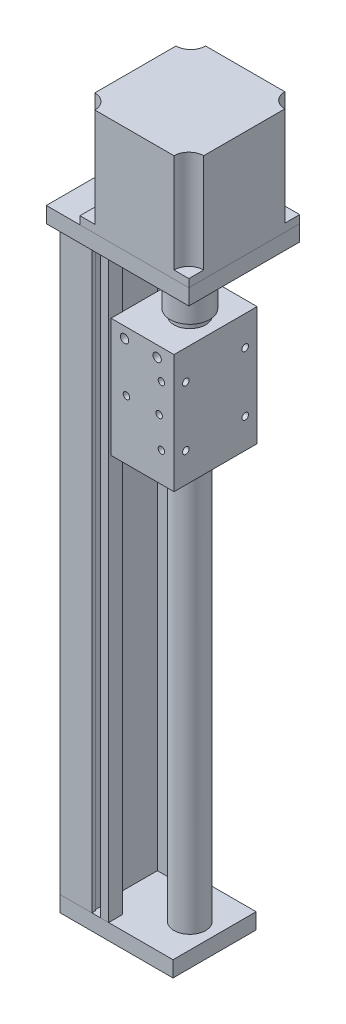
from build123d import *

# Parameters (mm, degrees)
SKETCH1_W                      = 57
SKETCH1_H                      = 42
BOSS_EXTRUDE1_DEPTH            = 8
BOSS_EXTRUDE2_DEPTH            = 297
SKETCH3_W                      = 72
SKETCH3_H                      = 56
BOSS_EXTRUDE3_DEPTH            = 8
SKETCH4_W                      = 55
SKETCH4_H                      = 56
BOSS_EXTRUDE4_DEPTH            = 54
CUT_EXTRUDE1_DEPTH             = 50
SKETCH6_R                      = 8
BOSS_EXTRUDE5_DEPTH            = 268.3
SKETCH7_W                      = 31.8
SKETCH7_H                      = 42
BOSS_EXTRUDE6_DEPTH            = 30
SKETCH8_R                      = 10
BOSS_EXTRUDE7_DEPTH            = 25
SKETCH9_R                      = 15
CUT_EXTRUDE2_DEPTH             = 5
BOSS_EXTRUDE8_REACH            = 67.7
SKETCH10_R                     = 3.175
SKETCH11_W                     = 4.3
SKETCH11_H                     = 297
CUT_EXTRUDE3_DEPTH             = 5.4
SKETCH12_W                     = 3.6
SKETCH12_H                     = 297
CUT_EXTRUDE4_DEPTH             = 2.7
SKETCH13_W                     = 4.3
SKETCH13_H                     = 297
CUT_EXTRUDE5_DEPTH             = 6.8
SKETCH14_W                     = 3.3
SKETCH14_H                     = 297
CUT_EXTRUDE6_DEPTH             = 3.4
M4X0_7_TAPPED_HOLE1_D          = 3.3
M4X0_7_TAPPED_HOLE1_DEPTH      = 10.1
M4X0_7_TAPPED_HOLE1_TIP        = 0.991420021
M4X0_7_TAPPED_HOLE2_AT_2_COUNT = 2
M4X0_7_TAPPED_HOLE2_AT_2_PITCH = 30
M4X0_7_TAPPED_HOLE2_AT_3_COUNT = 2
M4X0_7_TAPPED_HOLE2_AT_3_PITCH = 15.044018745
M4X0_7_TAPPED_HOLE2_AT_4_COUNT = 2
M4X0_7_TAPPED_HOLE2_AT_4_PITCH = 23.162955338
M5X0_8_TAPPED_HOLE1_AT_2_COUNT = 2
M5X0_8_TAPPED_HOLE1_AT_2_PITCH = 16.5


with BuildPart() as part:
    # Sketch1 → Boss-Extrude1 (new body)
    with BuildSketch(Plane(origin=(0, 0, 0), x_dir=(1, 0, 0), z_dir=(0, 1, 0))):
        with Locations((28.5, 0)):
            Rectangle(SKETCH1_W, SKETCH1_H)
    extrude(amount=BOSS_EXTRUDE1_DEPTH)

    # Sketch2 → Boss-Extrude2 (add)
    with BuildSketch(Plane(origin=(0, 8, 0), x_dir=(1, 0, 0), z_dir=(0, 1, 0))):
        Polygon((0, 21), (0, -21), (24.5, -21), (24.5, -14), (14.1, -14), (14.1, 14), (24.5, 14), (24.5, 21), align=None)
    extrude(amount=BOSS_EXTRUDE2_DEPTH)

    # Sketch3 → Boss-Extrude3 (add)
    with BuildSketch(Plane(origin=(0, 305, 0), x_dir=(1, 0, 0), z_dir=(0, 1, 0))):
        with Locations((36, 0)):
            Rectangle(SKETCH3_W, SKETCH3_H)
    extrude(amount=BOSS_EXTRUDE3_DEPTH)

    # Sketch4 → Boss-Extrude4 (add)
    with BuildSketch(Plane(origin=(0, 313, 0), x_dir=(1, 0, 0), z_dir=(0, 1, 0))):
        with Locations((44.5, 0)):
            Rectangle(SKETCH4_W, SKETCH4_H)
    extrude(amount=BOSS_EXTRUDE4_DEPTH)

    # Sketch5 → Cut-Extrude1 (cut)
    with BuildSketch(Plane(origin=(0, 367, 0), x_dir=(1, 0, 0), z_dir=(0, 1, 0))):
        with BuildLine():
            Line((17, 28), (17, 20.5))
            ThreePointArc((17, 20.5), (22.303300859, 22.696699141), (24.5, 28))
            Line((24.5, 28), (17, 28))
        make_face()
        with BuildLine():
            Line((72, 28), (64.5, 28))
            ThreePointArc((64.5, 28), (66.696699141, 22.696699141), (72, 20.5))
            Line((72, 20.5), (72, 28))
        make_face()
        with BuildLine():
            Line((72, -28), (72, -20.5))
            ThreePointArc((72, -20.5), (66.696699141, -22.696699141), (64.5, -28))
            Line((64.5, -28), (72, -28))
        make_face()
        with BuildLine():
            Line((17, -28), (24.5, -28))
            ThreePointArc((24.5, -28), (22.303300859, -22.696699141), (17, -20.5))
            Line((17, -20.5), (17, -28))
        make_face()
    extrude(amount=-CUT_EXTRUDE1_DEPTH, mode=Mode.SUBTRACT)

    # Sketch6 → Boss-Extrude5 (add)
    with BuildSketch(Plane(origin=(0, 8, 0), x_dir=(1, 0, 0), z_dir=(0, 1, 0))):
        with Locations((44.5, 0)):
            Circle(SKETCH6_R)
    extrude(amount=BOSS_EXTRUDE5_DEPTH)

    # Sketch7 → Boss-Extrude6 (add, symmetric)
    with BuildSketch(Plane(origin=(0, 243, 0), x_dir=(1, 0, 0), z_dir=(0, 1, 0))):
        with Locations((41.6, 0)):
            Rectangle(SKETCH7_W, SKETCH7_H)
    extrude(amount=BOSS_EXTRUDE6_DEPTH, both=True)

    # Sketch8 → Boss-Extrude7 (add)
    with BuildSketch(Plane(origin=(0, 276.3, 0), x_dir=(1, 0, 0), z_dir=(0, 1, 0))):
        with Locations((44.5, 0)):
            Circle(SKETCH8_R)
    extrude(amount=BOSS_EXTRUDE7_DEPTH)

    # Sketch9 → Cut-Extrude2 (cut)
    with BuildSketch(Plane.XZ.offset(-305)):
        with Locations((44.5, 0)):
            Circle(SKETCH9_R)
    extrude(amount=-CUT_EXTRUDE2_DEPTH, mode=Mode.SUBTRACT)

    # Sketch10 → Boss-Extrude8 (add, up to next)
    with BuildSketch(Plane(origin=(0, 301.3, 0), x_dir=(1, 0, 0), z_dir=(0, 1, 0)), mode=Mode.PRIVATE) as boss_extrude8_sk1:
        with Locations((44.5, 0)):
            Circle(SKETCH10_R)
    boss_extrude8_tool1 = extrude(boss_extrude8_sk1.sketch, amount=BOSS_EXTRUDE8_REACH, mode=Mode.PRIVATE) - part.part
    add(boss_extrude8_tool1.solids().sort_by_distance((44.5, 301.3, 0))[0])

    # Sketch11 → Cut-Extrude3 (cut)
    with BuildSketch(Plane(origin=(0, 0, -21), x_dir=(-1, 0, 0), z_dir=(0, 0, -1))):
        with Locations((-18.15, 156.5)):
            Rectangle(SKETCH11_W, SKETCH11_H)
    cut_extrude3 = extrude(amount=-CUT_EXTRUDE3_DEPTH, mode=Mode.SUBTRACT)

    # Sketch12 → Cut-Extrude4 (cut, symmetric)
    with BuildSketch(Plane(origin=(18.15, 0, 0), x_dir=(0, 0, -1), z_dir=(1, 0, 0))):
        with Locations((17.4, 156.5)):
            Rectangle(SKETCH12_W, SKETCH12_H)
    cut_extrude4 = extrude(amount=CUT_EXTRUDE4_DEPTH, both=True, mode=Mode.SUBTRACT)

    # Mirror1: Cut-Extrude3, Cut-Extrude4 across plane
    add(cut_extrude3.mirror(Plane.XY), mode=Mode.SUBTRACT)
    add(cut_extrude4.mirror(Plane.XY), mode=Mode.SUBTRACT)

    # Sketch13 → Cut-Extrude5 (cut)
    with BuildSketch(Plane.ZY):
        with Locations((15, 156.5)):
            Rectangle(SKETCH13_W, SKETCH13_H)
    cut_extrude5 = extrude(amount=-CUT_EXTRUDE5_DEPTH, mode=Mode.SUBTRACT)

    # Sketch14 → Cut-Extrude6 (cut, symmetric)
    with BuildSketch(Plane.XY.offset(15)):
        with Locations((3.65, 156.5)):
            Rectangle(SKETCH14_W, SKETCH14_H)
    cut_extrude6 = extrude(amount=CUT_EXTRUDE6_DEPTH, both=True, mode=Mode.SUBTRACT)

    # Mirror2: Cut-Extrude5, Cut-Extrude6 across plane
    add(cut_extrude5.mirror(Plane.XY), mode=Mode.SUBTRACT)
    add(cut_extrude6.mirror(Plane.XY), mode=Mode.SUBTRACT)

    # M4x0.7 Tapped Hole1
    with Locations(Plane(origin=(57.5, 0, 0), x_dir=(0, 0, -1), z_dir=(1, 0, 0))):
        with Locations((-15, 258), (15, 258), (15, 228), (-15, 228)):
            Hole(M4X0_7_TAPPED_HOLE1_D / 2, depth=M4X0_7_TAPPED_HOLE1_DEPTH)
            with Locations((0, 0, -(M4X0_7_TAPPED_HOLE1_DEPTH + M4X0_7_TAPPED_HOLE1_TIP / 2))):  # 118° drill point
                Cone(0, M4X0_7_TAPPED_HOLE1_D / 2, M4X0_7_TAPPED_HOLE1_TIP, mode=Mode.SUBTRACT)

    # Sketch23 → M4x0.7 Tapped Hole2 (revolve, cut)
    with BuildSketch(Plane(origin=(51.15, 228, 21), x_dir=(0, -1, 0), z_dir=(1, 0, 0))):
        Polygon((0, 0), (0, 6.991420021), (1.65, 6), (1.65, 0), align=None)
    m4x0_7_tapped_hole2 = revolve(axis=Axis((51.15, 228, 27.35), (0, 0, -1)), mode=Mode.SUBTRACT)

    # M4x0.7 Tapped Hole2 at 2: M4x0.7 Tapped Hole2 ×2
    with Locations(*[(0, i * M4X0_7_TAPPED_HOLE2_AT_2_PITCH, 0) for i in range(1, M4X0_7_TAPPED_HOLE2_AT_2_COUNT)]):
        add(m4x0_7_tapped_hole2, mode=Mode.SUBTRACT)

    # M4x0.7 Tapped Hole2 at 3: M4x0.7 Tapped Hole2 ×2
    with Locations(*[Vector(-0.07644234, 0.997074004, 0) * (i * M4X0_7_TAPPED_HOLE2_AT_3_PITCH) for i in range(1, M4X0_7_TAPPED_HOLE2_AT_3_COUNT)]):
        add(m4x0_7_tapped_hole2, mode=Mode.SUBTRACT)

    # M4x0.7 Tapped Hole2 at 4: M4x0.7 Tapped Hole2 ×2
    with Locations(*[Vector(-0.761992576, 0.647585758, 0) * (i * M4X0_7_TAPPED_HOLE2_AT_4_PITCH) for i in range(1, M4X0_7_TAPPED_HOLE2_AT_4_COUNT)]):
        add(m4x0_7_tapped_hole2, mode=Mode.SUBTRACT)

    # Sketch25 → M5x0.8 Tapped Hole1 (revolve, cut)
    with BuildSketch(Plane(origin=(32.5, 267.5, 21), x_dir=(0, -1, 0), z_dir=(1, 0, 0))):
        Polygon((0, 0), (0, 11.2618073), (2.1, 10), (2.1, 0), align=None)
    m5x0_8_tapped_hole1 = revolve(axis=Axis((32.5, 267.5, 27.35), (0, 0, -1)), mode=Mode.SUBTRACT)

    # M5x0.8 Tapped Hole1 at 2: M5x0.8 Tapped Hole1 ×2
    with Locations(*[(i * M5X0_8_TAPPED_HOLE1_AT_2_PITCH, 0, 0) for i in range(1, M5X0_8_TAPPED_HOLE1_AT_2_COUNT)]):
        add(m5x0_8_tapped_hole1, mode=Mode.SUBTRACT)

    # Mirror3: M5x0.8 Tapped Hole1, M4x0.7 Tapped Hole2 across plane
    add(m5x0_8_tapped_hole1.mirror(Plane.XY), mode=Mode.SUBTRACT)
    add(m4x0_7_tapped_hole2.mirror(Plane.XY), mode=Mode.SUBTRACT)

    # Mirror3 copy 1 sketch → Mirror3 copy 1 (revolve, cut)
    with BuildSketch(Plane(origin=(49, 267.5, -21), x_dir=(0, -1, 0), z_dir=(1, 0, 0))):
        Polygon((0, 0), (0, -11.2618073), (2.1, -10), (2.1, 0), align=None)
    revolve(axis=Axis((49, 267.5, -27.35), (0, 0, -1)), mode=Mode.SUBTRACT)

    # Mirror3 copy 2 sketch → Mirror3 copy 2 (revolve, cut)
    with BuildSketch(Plane(origin=(51.15, 258, -21), x_dir=(0, -1, 0), z_dir=(1, 0, 0))):
        Polygon((0, 0), (0, -6.991420021), (1.65, -6), (1.65, 0), align=None)
    revolve(axis=Axis((51.15, 258, -27.35), (0, 0, -1)), mode=Mode.SUBTRACT)

    # Mirror3 copy 3 sketch → Mirror3 copy 3 (revolve, cut)
    with BuildSketch(Plane(origin=(50, 243, -21), x_dir=(0, -1, 0), z_dir=(1, 0, 0))):
        Polygon((0, 0), (0, -6.991420021), (1.65, -6), (1.65, 0), align=None)
    revolve(axis=Axis((50, 243, -27.35), (0, 0, -1)), mode=Mode.SUBTRACT)

    # Mirror3 copy 4 sketch → Mirror3 copy 4 (revolve, cut)
    with BuildSketch(Plane(origin=(33.5, 243, -21), x_dir=(0, -1, 0), z_dir=(1, 0, 0))):
        Polygon((0, 0), (0, -6.991420021), (1.65, -6), (1.65, 0), align=None)
    revolve(axis=Axis((33.5, 243, -27.35), (0, 0, -1)), mode=Mode.SUBTRACT)


solid = part.part
